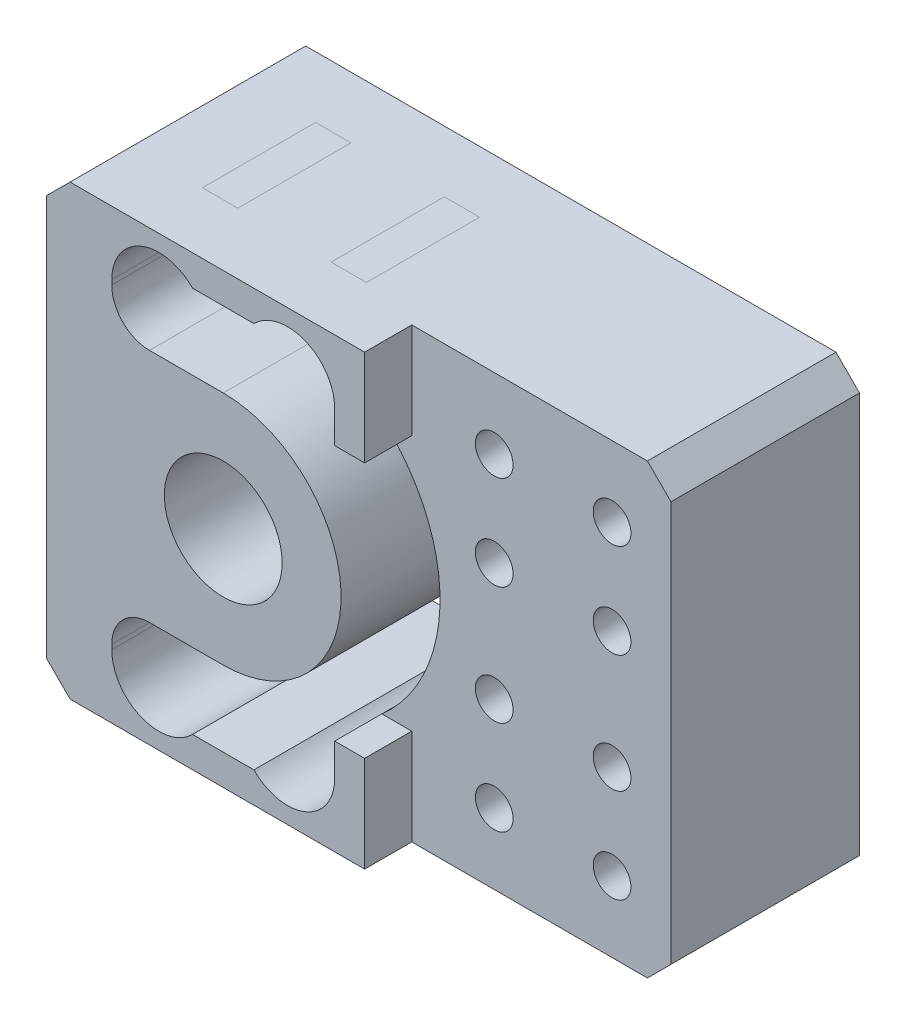
from build123d import *

# Parameters (mm, degrees)
SKETCH1_W                = 15
SKETCH1_H                = 19
BOSS_EXTRUDE1_DEPTH      = 5
BOSS_EXTRUDE1_DEPTH_BACK = 5
CUT_EXTRUDE1_START       = -6
SKETCH2_R                = 2
CUT_EXTRUDE1_DEPTH       = 16
SKETCH5_R                = 2
CUT_EXTRUDE4_DEPTH       = 17
CUT_EXTRUDE4_DEPTH_BACK  = 17
SKETCH6_R                = 2
CUT_EXTRUDE5_DEPTH       = 17
CUT_EXTRUDE5_DEPTH_BACK  = 17
SKETCH10_W               = 9.46
SKETCH10_H               = 13.6
CUT_EXTRUDE6_DEPTH       = 6
CUT_EXTRUDE6_DEPTH_BACK  = 6
BOSS_EXTRUDE2_START      = -5
SKETCH7_R                = 5
SKETCH7_R_2              = 2.5
BOSS_EXTRUDE2_DEPTH      = 10
BOSS_EXTRUDE3_DEPTH      = 5
FILLET1_R                = 1.6
SKETCH11_W               = 12.27
SKETCH11_H               = 19
BOSS_EXTRUDE4_DEPTH      = 10
CHAMFER1_SIZE            = 1
SKETCH16_W               = 5.80562201
SKETCH16_H               = 3.2
CUT_EXTRUDE8_DEPTH       = 11.5
CUT_EXTRUDE9_DEPTH       = 11.5
TROU_TARAUD_M21_D        = 1.6
SKETCH24_W               = 11
SKETCH24_H               = 19
CUT_EXTRUDE10_DEPTH      = 2
CUT_EXTRUDE11_DEPTH      = 2
TROU_TARAUD_M2_51_D      = 2.05
TROU_TARAUD_M2_51_DEPTH  = 8.25
TROU_TARAUD_M2_51_TIP    = 0.615882135


with BuildPart() as part:
    # Sketch1 → Boss-Extrude1 (new body, two sides)
    with BuildSketch(Plane.XY) as boss_extrude1_sk:
        Rectangle(SKETCH1_W, SKETCH1_H)
    extrude(amount=BOSS_EXTRUDE1_DEPTH)
    extrude(boss_extrude1_sk.sketch, amount=-BOSS_EXTRUDE1_DEPTH_BACK)

    # Sketch2 → Cut-Extrude1 (cut)
    with BuildSketch(Plane.XY.offset(CUT_EXTRUDE1_START)):
        with Locations((-2.73, 6.8)):
            Circle(SKETCH2_R)
    cut_extrude1 = extrude(amount=CUT_EXTRUDE1_DEPTH, mode=Mode.SUBTRACT)

    # Mirror3: Cut-Extrude1 across plane
    add(cut_extrude1.mirror(Plane.ZX), mode=Mode.SUBTRACT)

    # Sketch5 → Cut-Extrude4 (cut, two sides)
    with BuildSketch(Plane.XY) as cut_extrude4_sk:
        with Locations((2.73, 6.8)):
            Circle(SKETCH5_R)
    extrude(amount=CUT_EXTRUDE4_DEPTH, mode=Mode.SUBTRACT)
    extrude(cut_extrude4_sk.sketch, amount=-CUT_EXTRUDE4_DEPTH_BACK, mode=Mode.SUBTRACT)

    # Sketch6 → Cut-Extrude5 (cut, two sides)
    with BuildSketch(Plane.XY) as cut_extrude5_sk:
        with Locations((2.73, -6.8)):
            Circle(SKETCH6_R)
    extrude(amount=CUT_EXTRUDE5_DEPTH, mode=Mode.SUBTRACT)
    extrude(cut_extrude5_sk.sketch, amount=-CUT_EXTRUDE5_DEPTH_BACK, mode=Mode.SUBTRACT)

    # Sketch10 → Cut-Extrude6 (cut, two sides)
    with BuildSketch(Plane.XY) as cut_extrude6_sk:
        Rectangle(SKETCH10_W, SKETCH10_H)
    extrude(amount=CUT_EXTRUDE6_DEPTH, mode=Mode.SUBTRACT)
    extrude(cut_extrude6_sk.sketch, amount=-CUT_EXTRUDE6_DEPTH_BACK, mode=Mode.SUBTRACT)



with BuildPart() as body_2:
    # Sketch7 → Boss-Extrude2 (new body)
    with BuildSketch(Plane.XY.offset(BOSS_EXTRUDE2_START)):
        Circle(SKETCH7_R)
        Circle(SKETCH7_R_2, mode=Mode.SUBTRACT)
    extrude(amount=BOSS_EXTRUDE2_DEPTH)


with BuildPart() as part_1:
    add(part.part)

    add(body_2.part)  # Boss-Extrude3 merges body 2
    # Sketch8 → Boss-Extrude3 (add, symmetric)
    with BuildSketch(Plane.XY):
        Polygon((0, 5), (-7.5, 5), (-7.5, 0), (-5, 0), align=None)
    boss_extrude3 = extrude(amount=BOSS_EXTRUDE3_DEPTH, both=True)

    # Mirror7: Boss-Extrude3 across plane
    add(boss_extrude3.mirror(Plane.ZX))

    # Fillet1
    fillet1_edges = [part_1.edges().sort_by_distance(p)[0] for p in [
        (-4.73, -5, 0),
        (-4.73, 5, 0),
    ]]
    fillet(fillet1_edges, radius=FILLET1_R)

    # Sketch11 → Boss-Extrude4 (add)
    with BuildSketch(Plane.XY.offset(5)):
        with Locations((10.865, 0)):
            Rectangle(SKETCH11_W, SKETCH11_H)
    extrude(amount=-BOSS_EXTRUDE4_DEPTH)

    # Chamfer1
    chamfer1_edges = [part_1.edges().sort_by_distance(p)[0] for p in [
        (17, 9.5, 0),
        (17, -9.5, 0),
        (-7.5, 9.5, 0),
        (-7.5, -9.5, 0),
    ]]
    chamfer(chamfer1_edges, length=CHAMFER1_SIZE)

    # Sketch16 → Cut-Extrude8 (cut)
    with BuildSketch(Plane.XY.offset(5)):
        with Locations((-0.227188995, 6.6)):
            Rectangle(SKETCH16_W, SKETCH16_H)
    cut_extrude8 = extrude(amount=-CUT_EXTRUDE8_DEPTH, mode=Mode.SUBTRACT)

    # Mirror8: Cut-Extrude8 across plane
    add(cut_extrude8.mirror(Plane.ZX), mode=Mode.SUBTRACT)

    # Sketch17 → Cut-Extrude9 (cut)
    with BuildSketch(Plane.XY.offset(5)):
        with BuildLine():
            ThreePointArc((2.678170763, -4.222250746), (5, 0), (2.678170763, 4.222250746))
            ThreePointArc((2.678170763, 4.222250746), (2.338473166, 5.740343478), (3.856565898, 6.080041075))
            ThreePointArc((3.856565898, 6.080041075), (7.2, 0), (3.856565898, -6.080041075))
            ThreePointArc((3.856565898, -6.080041075), (2.338473166, -5.740343478), (2.678170763, -4.222250746))
        make_face()
    extrude(amount=-CUT_EXTRUDE9_DEPTH, mode=Mode.SUBTRACT)

    # Trou taraud_ M21 (through all)
    with Locations(Plane.XY.offset(5)):
        with Locations((14.5, 6.5), (14.5, -6.5), (9.5, 6.5), (9.5, -6.5), (9.5, 2.5), (14.5, 2.5), (14.5, -2.5), (9.5, -2.5)):
            Hole(TROU_TARAUD_M21_D / 2)

    # Sketch24 → Cut-Extrude10 (cut)
    with BuildSketch(Plane.XY.offset(5)):
        with Locations((11.5, 0)):
            Rectangle(SKETCH24_W, SKETCH24_H)
    extrude(amount=-CUT_EXTRUDE10_DEPTH, mode=Mode.SUBTRACT)

    # Sketch25 → Cut-Extrude11 (cut)
    with BuildSketch(Plane.XY.offset(5)):
        Polygon((17, -5.42836071), (4.73, -5.42836071), (6.865, 0), (4.73, 5.42836071), (17, 5.42836071), align=None)
    extrude(amount=-CUT_EXTRUDE11_DEPTH, mode=Mode.SUBTRACT)

    # Trou taraud_ M2.51
    with Locations(Plane.ZY.offset(7.5)):
        with Locations((0, 0)):
            Hole(TROU_TARAUD_M2_51_D / 2, depth=TROU_TARAUD_M2_51_DEPTH)
            with Locations((0, 0, -(TROU_TARAUD_M2_51_DEPTH + TROU_TARAUD_M2_51_TIP / 2))):  # 118° drill point
                Cone(0, TROU_TARAUD_M2_51_D / 2, TROU_TARAUD_M2_51_TIP, mode=Mode.SUBTRACT)


solid = part_1.part
